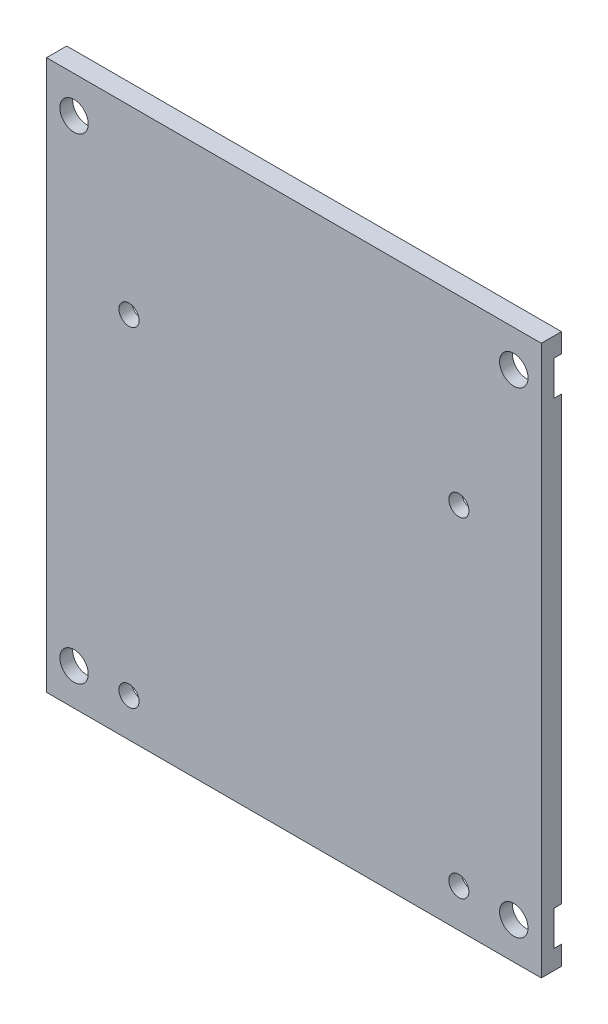
from build123d import *

# Parameters (mm, degrees)
SKETCH_1_W          = 54
SKETCH_1_H          = 60
SKETCH_1_R          = 1.1
EXTRUDE_1_DEPTH     = 2.2
SKETCH_2_R          = 3
SKETCH_2_R_2        = 2.929560398
CUT_EXTRUDE_1_DEPTH = 0.8
SKETCH_3_R          = 1.1
SKETCH_3_R_2        = 1.55
CUT_EXTRUDE_2_DEPTH = 3.2
SKETCH_4_R          = 3.55
SKETCH_4_R_2        = 1.55
CUT_EXTRUDE_3_DEPTH = 0.8


with BuildPart() as part:
    # 草图1 → 凸台-拉伸1 (new body)
    with BuildSketch(Plane.XY):
        Rectangle(SKETCH_1_W, SKETCH_1_H)
        with Locations((-18, -25.8)):
            Circle(SKETCH_1_R, mode=Mode.SUBTRACT)
        with Locations((18, -25.8)):
            Circle(SKETCH_1_R, mode=Mode.SUBTRACT)
        with Locations((-18, 10.2)):
            Circle(SKETCH_1_R, mode=Mode.SUBTRACT)
        with Locations((18, 10.2)):
            Circle(SKETCH_1_R, mode=Mode.SUBTRACT)
    extrude(amount=EXTRUDE_1_DEPTH)

    # 草图2 → 切除-拉伸1 (cut)
    with BuildSketch(Plane(origin=(0, 0, 0), x_dir=(-1, 0, 0), z_dir=(0, 0, -1))):
        with Locations((-18, 10.2)):
            Circle(SKETCH_2_R)
        with Locations((18, 10.2)):
            Circle(SKETCH_2_R)
        with Locations((-18, -25.8)):
            Circle(SKETCH_2_R_2)
        with Locations((18, -25.8)):
            Circle(SKETCH_2_R)
    extrude(amount=-CUT_EXTRUDE_1_DEPTH, mode=Mode.SUBTRACT)

    # 草图3 → 切除-拉伸2 (cut, through all)
    with BuildSketch(Plane.XY.offset(2.2)):
        with Locations((-18, -25.8)):
            Circle(SKETCH_3_R)
        with Locations((-24, -26)):
            Circle(SKETCH_3_R_2)
        with Locations((-24, 26)):
            Circle(SKETCH_3_R_2)
        with Locations((24, -26)):
            Circle(SKETCH_3_R_2)
        with Locations((24, 26)):
            Circle(SKETCH_3_R_2)
    extrude(amount=-CUT_EXTRUDE_2_DEPTH, mode=Mode.SUBTRACT)

    # 草图4 → 切除-拉伸3 (cut)
    with BuildSketch(Plane(origin=(0, 0, 0), x_dir=(-1, 0, 0), z_dir=(0, 0, -1))):
        with Locations((-24, 26)):
            Circle(SKETCH_4_R)
        with Locations((-24, 26)):
            Circle(SKETCH_4_R_2, mode=Mode.SUBTRACT)
        with Locations((24, 26)):
            Circle(SKETCH_4_R)
        with Locations((24, 26)):
            Circle(SKETCH_4_R_2, mode=Mode.SUBTRACT)
        with Locations((24, -26)):
            Circle(SKETCH_4_R)
        with Locations((24, -26)):
            Circle(SKETCH_4_R_2, mode=Mode.SUBTRACT)
        with Locations((-24, -26)):
            Circle(SKETCH_4_R)
        with Locations((-24, -26)):
            Circle(SKETCH_4_R_2, mode=Mode.SUBTRACT)
    extrude(amount=-CUT_EXTRUDE_3_DEPTH, mode=Mode.SUBTRACT)


solid = part.part
